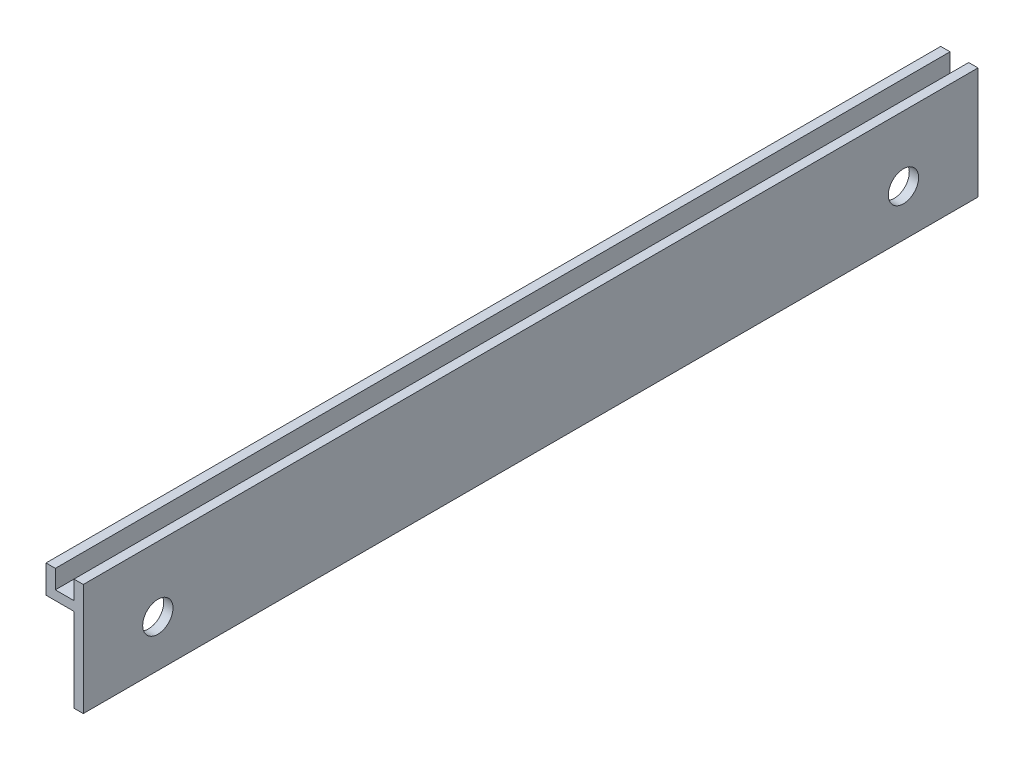
from build123d import *

# Parameters (mm, degrees)
BOSS_EXTRUDE1_DEPTH = 152.4
SKETCH2_R           = 2.5796875
CUT_EXTRUDE1_DEPTH  = 2.5875


with BuildPart() as part:
    # Sketch1 → Boss-Extrude1 (new body)
    with BuildSketch(Plane.XY):
        Polygon((-6.35, 19.05), (-4.7625, 19.05), (-4.7625, 15.875), (-1.5875, 15.875), (-1.5875, 19.05), (0, 19.05), (0, 0), (-1.5875, 0), (-1.5875, 14.2875), (-6.35, 14.2875), align=None)
    extrude(amount=BOSS_EXTRUDE1_DEPTH)

    # Sketch2 → Cut-Extrude1 (cut, through all)
    with BuildSketch(Plane.ZY.offset(1.5875)):
        with Locations((12.7, 7.9375)):
            Circle(SKETCH2_R)
        with Locations((139.7, 7.9375)):
            Circle(SKETCH2_R)
    extrude(amount=-CUT_EXTRUDE1_DEPTH, mode=Mode.SUBTRACT)


solid = part.part
